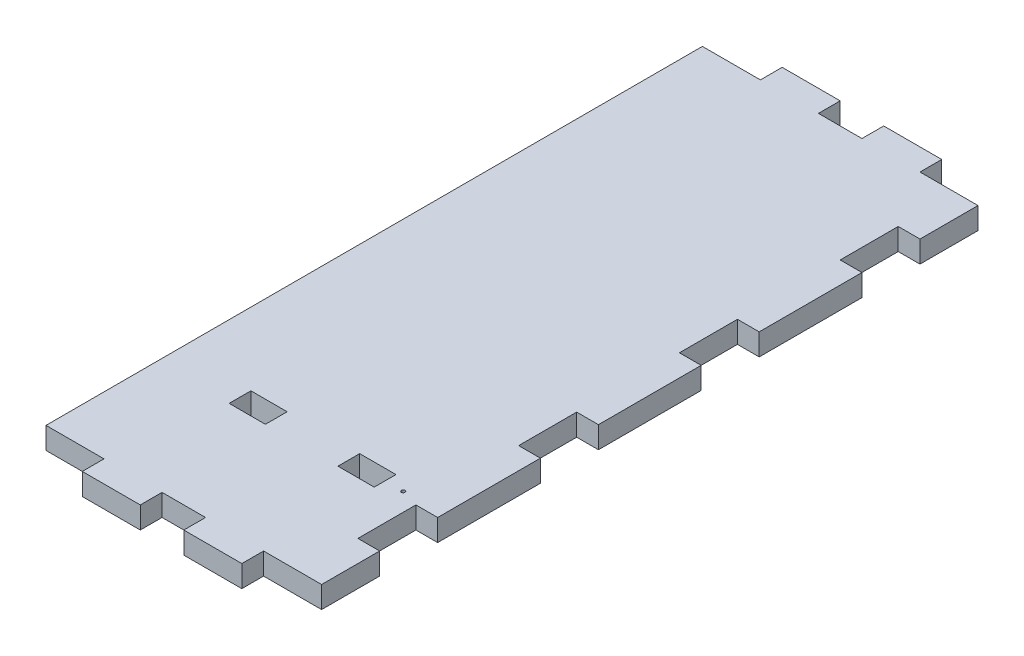
from build123d import *

# Parameters (mm, degrees)
SKETCH1_W           = 60
SKETCH1_H           = 193
SKETCH1_W_2         = 10
BOSS_EXTRUDE1_DEPTH = 6
SKETCH4_W           = 6
SKETCH4_H           = 193
BOSS_EXTRUDE2_DEPTH = 6
SKETCH5_W           = 6
SKETCH5_H           = 16
SKETCH5_W_2         = 16
SKETCH5_H_2         = 6
SKETCH5_W_3         = 12
CUT_EXTRUDE1_DEPTH  = 7
SKETCH6_R           = 0.5
SKETCH6_W           = 10
SKETCH6_H           = 6
CUT_EXTRUDE2_DEPTH  = 7


with BuildPart() as part:
    # Sketch1 → Boss-Extrude1 (new body)
    with BuildSketch(Plane(origin=(0, 0, 0), x_dir=(1, 0, 0), z_dir=(0, 1, 0))):
        with Locations((5, 0)):
            Rectangle(SKETCH1_W, SKETCH1_H)
        with Locations((-30, 0)):
            Rectangle(SKETCH1_W_2, SKETCH1_H)
    extrude(amount=BOSS_EXTRUDE1_DEPTH)

    # Sketch4 → Boss-Extrude2 (add)
    with BuildSketch(Plane(origin=(0, 6, 0), x_dir=(1, 0, 0), z_dir=(0, 1, 0))):
        with Locations((38, 0)):
            Rectangle(SKETCH4_W, SKETCH4_H)
    extrude(amount=-BOSS_EXTRUDE2_DEPTH)

    # Sketch5 → Cut-Extrude1 (cut, through all)
    with BuildSketch(Plane(origin=(0, 6, 0), x_dir=(1, 0, 0), z_dir=(0, 1, 0))):
        with Locations((38, -66.5)):
            Rectangle(SKETCH5_W, SKETCH5_H)
        Polygon((35, -30.166666667), (41, -30.166666667), (41, -14.166666667), (38, -14.166666667), (35, -14.166666667), align=None)
        with Locations((33, -93.5)):
            Rectangle(SKETCH5_W_2, SKETCH5_H_2)
        with Locations((-27, -93.5)):
            Rectangle(SKETCH5_W_2, SKETCH5_H_2)
        with Locations((3, -93.5)):
            Rectangle(SKETCH5_W_3, SKETCH5_H_2)
    cut_extrude1 = extrude(amount=-CUT_EXTRUDE1_DEPTH, mode=Mode.SUBTRACT)

    # Mirror1: Cut-Extrude1 across plane
    add(cut_extrude1.mirror(Plane.XY), mode=Mode.SUBTRACT)

    # Sketch6 → Cut-Extrude2 (cut, through all)
    with BuildSketch(Plane(origin=(0, 6, 0), x_dir=(1, 0, 0), z_dir=(0, 1, 0))):
        with Locations((30, -57)):
            Circle(SKETCH6_R)
        with Locations((20, -57)):
            Rectangle(SKETCH6_W, SKETCH6_H)
        with Locations((-10, -57)):
            Rectangle(SKETCH6_W, SKETCH6_H)
    extrude(amount=-CUT_EXTRUDE2_DEPTH, mode=Mode.SUBTRACT)


solid = part.part
